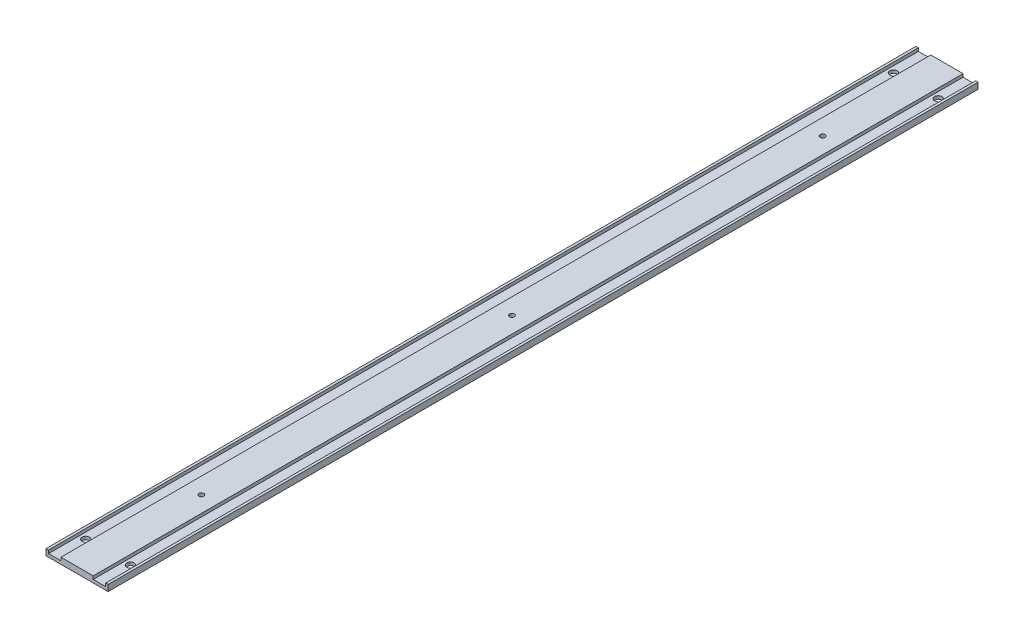
from build123d import *

# Parameters (mm, degrees)
SKETCH1_W           = 50
SKETCH1_H           = 700
BOSS_EXTRUDE1_DEPTH = 5
SKETCH3_R           = 2
CUT_EXTRUDE1_DEPTH  = 6
SKETCH5_W           = 10
SKETCH5_H           = 700
CUT_EXTRUDE2_DEPTH  = 2.5
SKETCH6_R           = 3
CUT_EXTRUDE3_DEPTH  = 6


with BuildPart() as part:
    # Sketch1 → Boss-Extrude1 (new body)
    with BuildSketch(Plane(origin=(0, 0, 0), x_dir=(1, 0, 0), z_dir=(0, 1, 0))):
        with Locations((25, 350)):
            Rectangle(SKETCH1_W, SKETCH1_H)
    extrude(amount=BOSS_EXTRUDE1_DEPTH)

    # Sketch3 → Cut-Extrude1 (cut, through all)
    with BuildSketch(Plane(origin=(0, 5, 0), x_dir=(1, 0, 0), z_dir=(0, 1, 0))):
        with Locations((25, 600)):
            Circle(SKETCH3_R)
        with Locations((25, 350)):
            Circle(SKETCH3_R)
        with Locations((25, 100)):
            Circle(SKETCH3_R)
    extrude(amount=-CUT_EXTRUDE1_DEPTH, mode=Mode.SUBTRACT)

    # Sketch5 → Cut-Extrude2 (cut)
    with BuildSketch(Plane(origin=(0, 5, 0), x_dir=(1, 0, 0), z_dir=(0, 1, 0))):
        with Locations((7, 350)):
            Rectangle(SKETCH5_W, SKETCH5_H)
        with Locations((43, 350)):
            Rectangle(SKETCH5_W, SKETCH5_H)
    extrude(amount=-CUT_EXTRUDE2_DEPTH, mode=Mode.SUBTRACT)

    # Sketch6 → Cut-Extrude3 (cut, through all)
    with BuildSketch(Plane(origin=(0, 5, 0), x_dir=(1, 0, 0), z_dir=(0, 1, 0))):
        with Locations((43, 25)):
            Circle(SKETCH6_R)
        with Locations((7, 25)):
            Circle(SKETCH6_R)
        with Locations((43, 675)):
            Circle(SKETCH6_R)
        with Locations((7, 675)):
            Circle(SKETCH6_R)
    extrude(amount=-CUT_EXTRUDE3_DEPTH, mode=Mode.SUBTRACT)


solid = part.part
